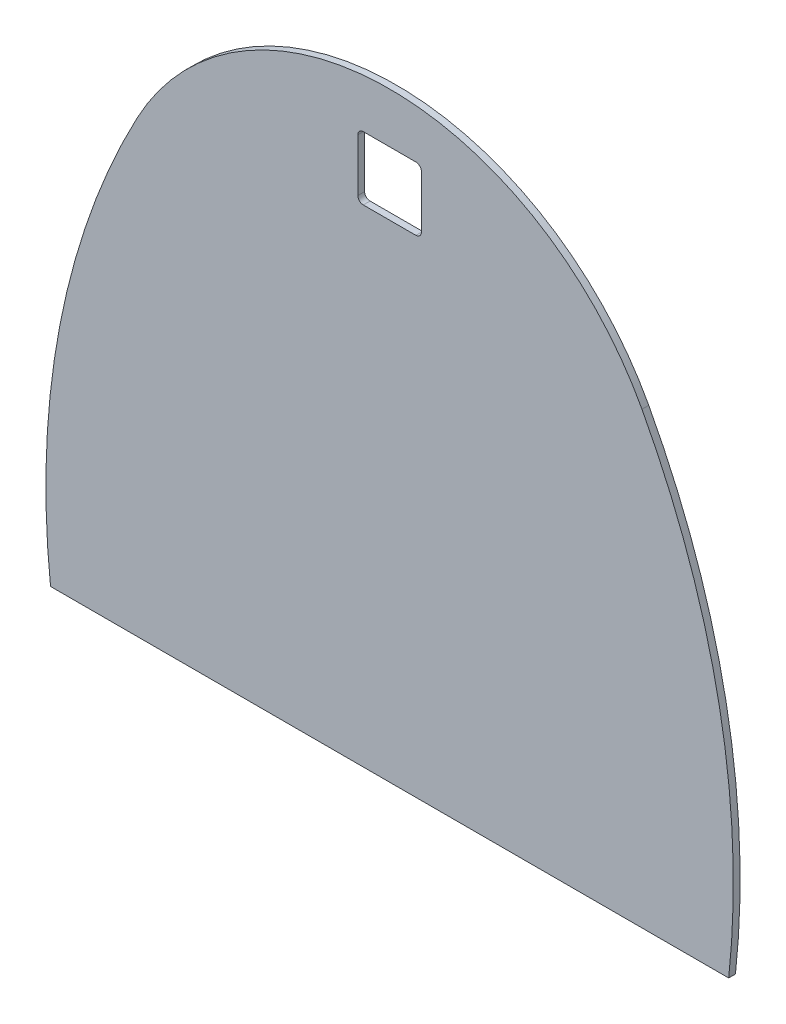
from build123d import *

# Parameters (mm, degrees)
BOSS_EXTRUDE1_DEPTH = 3.175
CUT_EXTRUDE1_REACH  = 325.245
SKETCH2_W           = 29.718
SKETCH2_H           = 29.718
FILLET1_R           = 2.54


with BuildPart() as part:
    # Sketch1 → Boss-Extrude1 (new body)
    with BuildSketch(Plane.XY):
        with BuildLine():
            ThreePointArc((118.128585461, 209.55), (0, 280.345753402), (-118.128585461, 209.55))
            ThreePointArc((-118.128585461, 209.55), (-154.323359707, 107.497469491), (-158.711897248, -0.694588462))
            Line((-158.711897248, -0.694588462), (158.711897248, -0.694588462))
            ThreePointArc((158.711897248, -0.694588462), (154.323359707, 107.497469491), (118.128585461, 209.55))
        make_face()
    extrude(amount=BOSS_EXTRUDE1_DEPTH)

    # Sketch2 → Cut-Extrude1 (cut, up to next)
    with BuildSketch(Plane.XY.offset(3.175), mode=Mode.PRIVATE) as cut_extrude1_sk1:
        with Locations((0, 242.002411538)):
            Rectangle(SKETCH2_W, SKETCH2_H)
    cut_extrude1_tool1 = extrude(cut_extrude1_sk1.sketch, amount=-CUT_EXTRUDE1_REACH, mode=Mode.PRIVATE) & part.part
    add(cut_extrude1_tool1.solids().sort_by_distance((0, 242.002412, 3.175))[0], mode=Mode.SUBTRACT)

    # Fillet1
    fillet1_edges = [part.edges().sort_by_distance(p)[0] for p in [
        (14.859, 227.143411538, 1.5875),
        (14.859, 256.861411538, 1.5875),
        (-14.859, 256.861411538, 1.5875),
        (-14.859, 227.143411538, 1.5875),
    ]]
    fillet(fillet1_edges, radius=FILLET1_R)


solid = part.part
